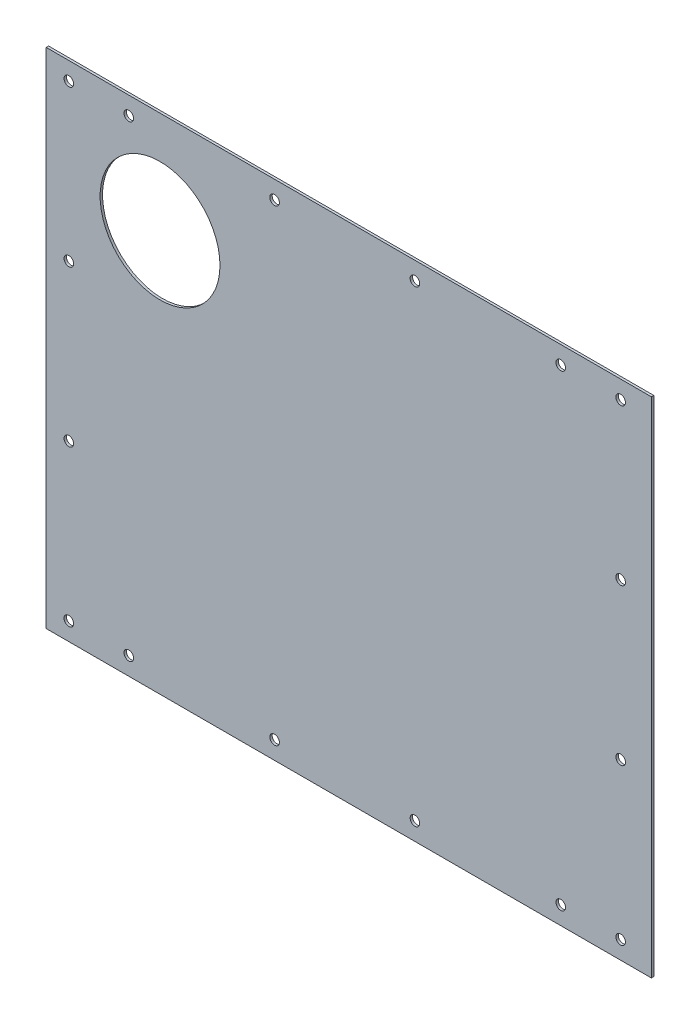
from build123d import *

# Parameters (mm, degrees)
ESQUISSE1_W             = 505
ESQUISSE1_H             = 420
BOSS_EXTRU_1_DEPTH      = 2
ESQUISSE2_R             = 50
ENL_V_MAT_EXTRU_1_DEPTH = 10
ESQUISSE3_R             = 4
ENL_V_MAT_EXTRU_2_DEPTH = 10


with BuildPart() as part:
    # Esquisse1 → Boss.-Extru.1 (new body)
    with BuildSketch(Plane.XY):
        with Locations((0, 2.5)):
            Rectangle(ESQUISSE1_W, ESQUISSE1_H)
    extrude(amount=BOSS_EXTRU_1_DEPTH)

    # Esquisse2 → Enlèv. mat.-Extru.1 (cut)
    with BuildSketch(Plane.XY.offset(2)):
        with Locations((-157.5, 127.5)):
            Circle(ESQUISSE2_R)
    extrude(amount=-ENL_V_MAT_EXTRU_1_DEPTH, mode=Mode.SUBTRACT)

    # Esquisse3 → Enlèv. mat.-Extru.2 (cut)
    with BuildSketch(Plane.XY.offset(2)):
        with Locations((-233.6, 197.5)):
            Circle(ESQUISSE3_R)
        with Locations((-183.6, 197.5)):
            Circle(ESQUISSE3_R)
        with Locations((-61.93, 197.5)):
            Circle(ESQUISSE3_R)
        with Locations((55.17, 197.5)):
            Circle(ESQUISSE3_R)
        with Locations((176.84, 197.5)):
            Circle(ESQUISSE3_R)
        with Locations((226.84, 197.5)):
            Circle(ESQUISSE3_R)
        with Locations((226.84, 67.5)):
            Circle(ESQUISSE3_R)
        with Locations((226.84, -62.5)):
            Circle(ESQUISSE3_R)
        with Locations((226.84, -192.5)):
            Circle(ESQUISSE3_R)
        with Locations((176.84, -192.5)):
            Circle(ESQUISSE3_R)
        with Locations((55.17, -192.5)):
            Circle(ESQUISSE3_R)
        with Locations((-61.93, -192.5)):
            Circle(ESQUISSE3_R)
        with Locations((-183.6, -192.5)):
            Circle(ESQUISSE3_R)
        with Locations((-233.6, -192.5)):
            Circle(ESQUISSE3_R)
        with Locations((-233.6, -62.5)):
            Circle(ESQUISSE3_R)
        with Locations((-233.6, 67.5)):
            Circle(ESQUISSE3_R)
    extrude(amount=-ENL_V_MAT_EXTRU_2_DEPTH, mode=Mode.SUBTRACT)


solid = part.part
